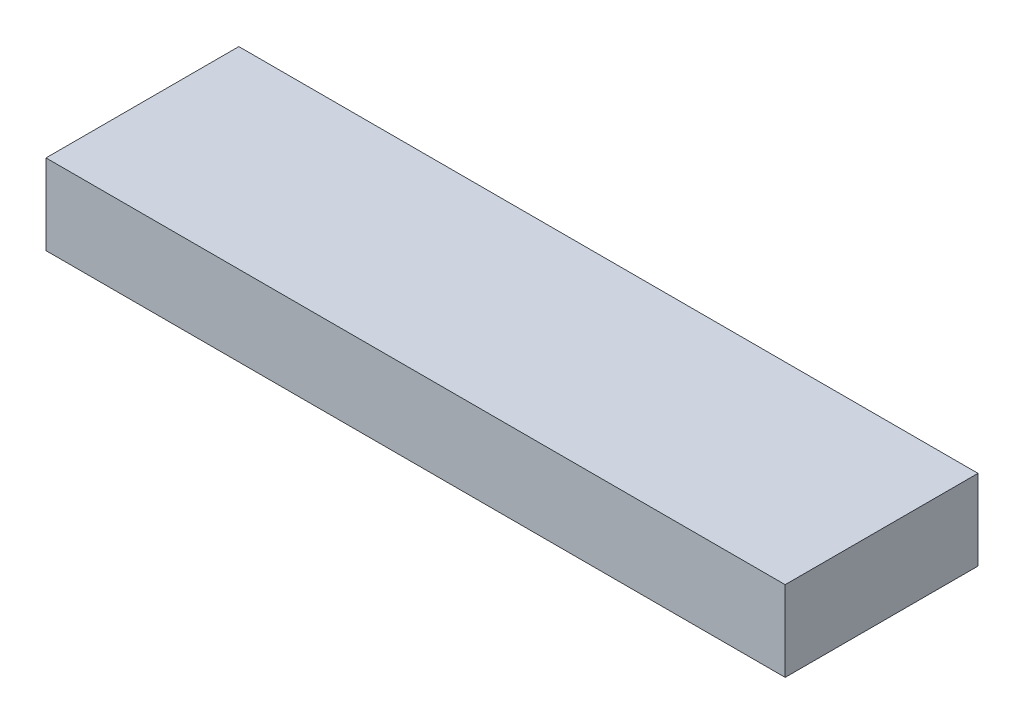
from build123d import *

# Parameters (mm, degrees)
SKETCH1_W           = 46
SKETCH1_H           = 12
BOSS_EXTRUDE1_DEPTH = 5


with BuildPart() as part:
    # Sketch1 → Boss-Extrude1 (new body)
    with BuildSketch(Plane(origin=(0, 0, 0), x_dir=(1, 0, 0), z_dir=(0, 1, 0))):
        with Locations((8.357142857, 4.5)):
            Rectangle(SKETCH1_W, SKETCH1_H)
    extrude(amount=BOSS_EXTRUDE1_DEPTH)


solid = part.part
